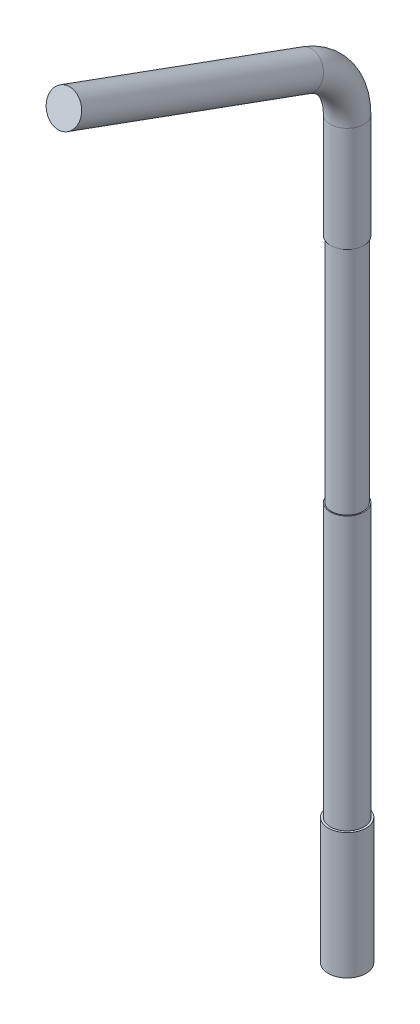
from build123d import *

# Parameters (mm, degrees)
SKETCH2_R         = 0.8
SKETCH4_R         = 0.9
EXTRUDE1_DEPTH    = 6
SKETCH5_OUTSIDE_W = 12.85
SKETCH5_OUTSIDE_H = 25.724
SKETCH5_OUTSIDE_R = 0.75
EXTRUDE3_DEPTH    = 11


with BuildPart() as part:
    # Sweep1: sweep along a path in Sketch1
    with BuildLine(Plane(origin=(0, 0, 0), x_dir=(0, 0, -1), z_dir=(1, 0, 0))) as sweep1_path:
        Line((4.5, 0), (4.5, 35))
        ThreePointArc((4.5, 35), (3.957456133, 36.720729309), (2.52606043, 37.819077862))
        Line((2.52606043, 37.819077862), (-9, 42.014220777))
    # Sketch2 → Sweep1 (sweep)
    with BuildSketch(Plane(origin=(0, 0, 0), x_dir=(1, 0, 0), z_dir=(0, 1, 0))):
        with Locations((0, 4.5)):
            Circle(SKETCH2_R)
    sweep(path=sweep1_path.line)

    # Sketch4 → Extrude1 (add)
    with BuildSketch(Plane(origin=(0, 0, 0), x_dir=(1, 0, 0), z_dir=(0, 1, 0))):
        with Locations((0, 4.5)):
            Circle(SKETCH4_R)
    extrude(amount=EXTRUDE1_DEPTH)

    # Sketch5 outside → Extrude3 (cut)
    with BuildSketch(Plane(origin=(0, 19, 0), x_dir=(-1, 0, 0), z_dir=(0, 1, 0))):
        with Locations((0, 1.937)):
            Rectangle(SKETCH5_OUTSIDE_W, SKETCH5_OUTSIDE_H)
        with Locations((0, -4.5)):
            Circle(SKETCH5_OUTSIDE_R, mode=Mode.SUBTRACT)
    extrude(amount=EXTRUDE3_DEPTH, mode=Mode.SUBTRACT)


solid = part.part
